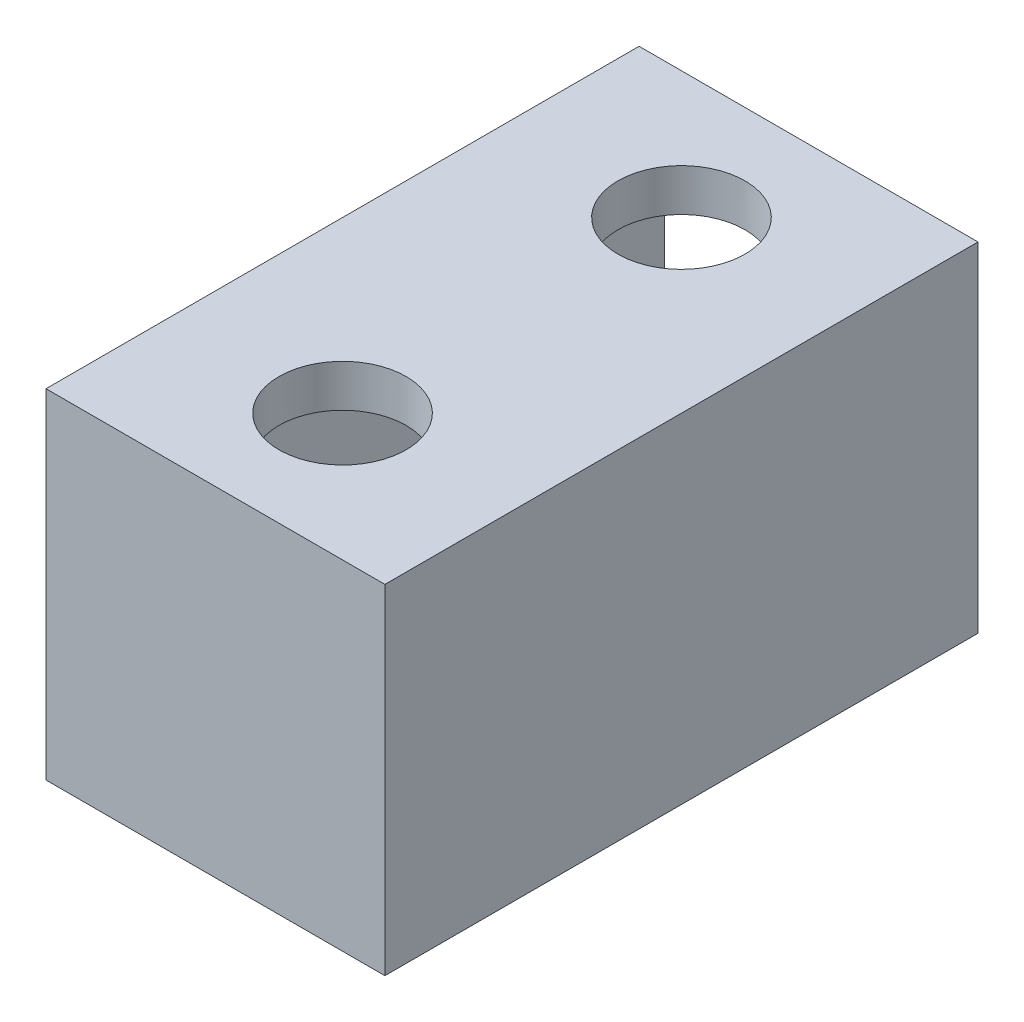
from build123d import *

# Parameters (mm, degrees)
SKETCH1_W           = 40
SKETCH1_H           = 40
SKETCH1_W_2         = 34
SKETCH1_H_2         = 34
BOSS_EXTRUDE1_DEPTH = 70
SKETCH2_W           = 34
SKETCH2_H           = 3
BOSS_EXTRUDE2_DEPTH = 37
CUT_EXTRUDE1_DEPTH  = 37
SKETCH4_R           = 8.5
SKETCH4_R_2         = 7.5
BOSS_EXTRUDE3_DEPTH = 2
SKETCH6_R           = 7.5
BOSS_EXTRUDE4_DEPTH = 10
FILLET2_R           = 1.5
FILLET3_R           = 1.5
FILLET4_R           = 1.5
FILLET5_R           = 1.5
BOSS_EXTRUDE5_DEPTH = 2


with BuildPart() as part:
    # Sketch1 → Boss-Extrude1 (new body)
    with BuildSketch(Plane.XY):
        with Locations((-20, 20)):
            Rectangle(SKETCH1_W, SKETCH1_H)
        with Locations((-20, 20)):
            Rectangle(SKETCH1_W_2, SKETCH1_H_2, mode=Mode.SUBTRACT)
    extrude(amount=BOSS_EXTRUDE1_DEPTH)

    # Sketch2 → Boss-Extrude2 (add)
    with BuildSketch(Plane(origin=(0, 37, 0), x_dir=(-1, 0, 0), z_dir=(0, -1, 0))):
        with Locations((20, -68.5)):
            Rectangle(SKETCH2_W, SKETCH2_H)
    extrude(amount=BOSS_EXTRUDE2_DEPTH)

    # Sketch3 → Cut-Extrude1 (cut)
    with BuildSketch(Plane(origin=(0, 40, 0), x_dir=(1, 0, 0), z_dir=(0, 1, 0))):
        with BuildLine():
            ThreePointArc((-12.5, -15), (-14.696699141, -9.696699141), (-20, -7.5))
            Line((-20, -7.5), (-20, -15))
            Line((-20, -15), (-12.5, -15))
        make_face()
        with BuildLine():
            Line((-20, -15), (-20, -7.5))
            ThreePointArc((-20, -7.5), (-25.303300859, -9.696699141), (-27.5, -15))
            Line((-27.5, -15), (-20, -15))
        make_face()
        with BuildLine():
            Line((-12.5, -15), (-20, -15))
            Line((-20, -15), (-20, -22.5))
            ThreePointArc((-20, -22.5), (-14.696699141, -20.303300859), (-12.5, -15))
        make_face()
        with BuildLine():
            Line((-20, -22.5), (-20, -15))
            Line((-20, -15), (-27.5, -15))
            ThreePointArc((-27.5, -15), (-25.303300859, -20.303300859), (-20, -22.5))
        make_face()
        with BuildLine():
            ThreePointArc((-12.5, -55), (-14.696699141, -49.696699141), (-20, -47.5))
            Line((-20, -47.5), (-20, -55))
            Line((-20, -55), (-12.5, -55))
        make_face()
        with BuildLine():
            Line((-20, -55), (-20, -47.5))
            ThreePointArc((-20, -47.5), (-25.303300859, -49.696699141), (-27.5, -55))
            Line((-27.5, -55), (-20, -55))
        make_face()
        with BuildLine():
            Line((-12.5, -55), (-20, -55))
            Line((-20, -55), (-20, -62.5))
            ThreePointArc((-20, -62.5), (-14.696699141, -60.303300859), (-12.5, -55))
        make_face()
        with BuildLine():
            Line((-20, -62.5), (-20, -55))
            Line((-20, -55), (-27.5, -55))
            ThreePointArc((-27.5, -55), (-25.303300859, -60.303300859), (-20, -62.5))
        make_face()
    extrude(amount=-CUT_EXTRUDE1_DEPTH, mode=Mode.SUBTRACT)

    # Sketch4 → Boss-Extrude3 (add)
    with BuildSketch(Plane(origin=(0, 37, 0), x_dir=(-1, 0, 0), z_dir=(0, -1, 0))):
        with Locations((20, -15)):
            Circle(SKETCH4_R)
        with Locations((20, -15)):
            Circle(SKETCH4_R_2, mode=Mode.SUBTRACT)
        with Locations((20, -55)):
            Circle(SKETCH4_R)
        with Locations((20, -55)):
            Circle(SKETCH4_R_2, mode=Mode.SUBTRACT)
    extrude(amount=BOSS_EXTRUDE3_DEPTH)

    # Sketch6 → Boss-Extrude4 (add)
    with BuildSketch(Plane(origin=(0, 3, 0), x_dir=(1, 0, 0), z_dir=(0, 1, 0))):
        with Locations((-20, -15)):
            Circle(SKETCH6_R)
        with Locations((-20, -55)):
            Circle(SKETCH6_R)
    extrude(amount=-BOSS_EXTRUDE4_DEPTH)

    # Fillet2
    fillet2_edges = [part.edges().sort_by_distance(p)[0] for p in [
        (-27.5, -7, 55),
    ]]
    fillet(fillet2_edges, radius=FILLET2_R)

    # Fillet3
    fillet3_edges = [part.edges().sort_by_distance(p)[0] for p in [
        (-27.5, -7, 15),
    ]]
    fillet(fillet3_edges, radius=FILLET3_R)

    # Fillet4
    fillet4_edges = [part.edges().sort_by_distance(p)[0] for p in [
        (-27.5, 0, 15),
    ]]
    fillet(fillet4_edges, radius=FILLET4_R)

    # Fillet5
    fillet5_edges = [part.edges().sort_by_distance(p)[0] for p in [
        (-27.5, 0, 55),
    ]]
    fillet(fillet5_edges, radius=FILLET5_R)

    # Sketch9 → Boss-Extrude5 (add)
    with BuildSketch(Plane.ZY.offset(40)):
        Polygon((35, 30.488163829), (37.465362362, 28.022801468), (36.232681181, 28.022801468), (36.232681181, 12.265663865), (33.412251244, 12.265663865), (33.412251244, 28.022801468), (32.534637638, 28.022801468), align=None)
    extrude(amount=BOSS_EXTRUDE5_DEPTH)


solid = part.part
